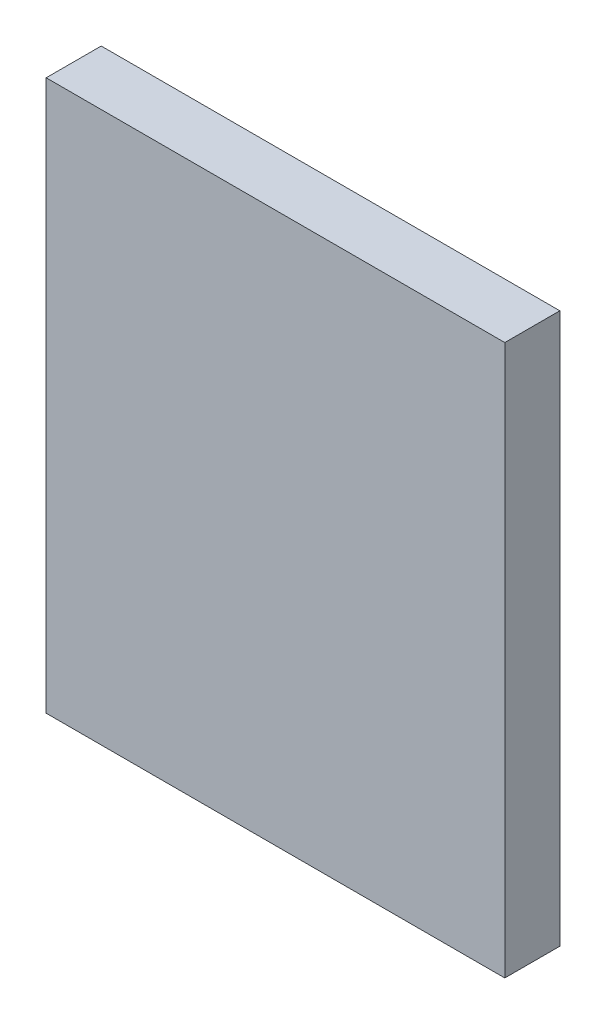
from build123d import *

# Parameters (mm, degrees)
SKETCH_1_W      = 50
SKETCH_1_H      = 60
EXTRUDE_1_DEPTH = 6


with BuildPart() as part:
    # 草图1 → 凸台-拉伸1 (new body)
    with BuildSketch(Plane.XY):
        with Locations((4.118329466, -21.009280742)):
            Rectangle(SKETCH_1_W, SKETCH_1_H)
    extrude(amount=EXTRUDE_1_DEPTH)


solid = part.part
